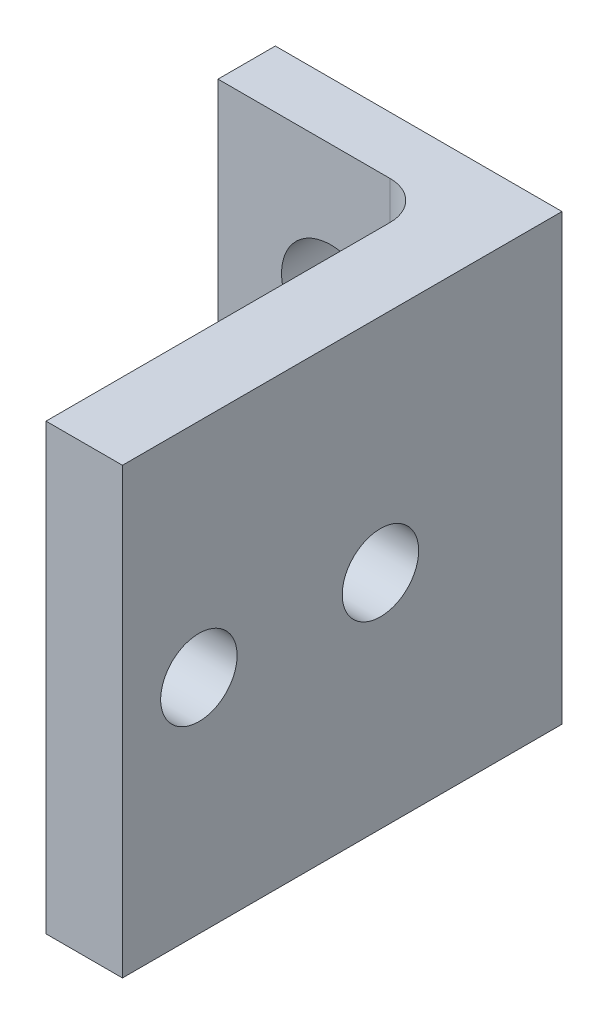
from build123d import *

# Parameters (mm, degrees)
SKETCH1_W           = 15
SKETCH1_H           = 23.236534363
SKETCH1_R           = 2.58
BOSS_EXTRUDE1_DEPTH = 3
SKETCH2_W           = 4
SKETCH2_H           = 23.236534363
BOSS_EXTRUDE2_DEPTH = 20
SKETCH3_R           = 2
CUT_EXTRUDE1_DEPTH  = 4
FILLET1_R           = 2
SKETCH4_R           = 4.75
CUT_EXTRUDE2_DEPTH  = 4


with BuildPart() as part:
    # Sketch1 → Boss-Extrude1 (new body)
    with BuildSketch(Plane.XY):
        with Locations((57.83, 7.038267182)):
            Rectangle(SKETCH1_W, SKETCH1_H)
        with Locations((56.235, 11.52)):
            Circle(SKETCH1_R, mode=Mode.SUBTRACT)
    extrude(amount=BOSS_EXTRUDE1_DEPTH)

    # Sketch2 → Boss-Extrude2 (add)
    with BuildSketch(Plane.XY.offset(3)):
        with Locations((63.33, 7.038267182)):
            Rectangle(SKETCH2_W, SKETCH2_H)
    extrude(amount=BOSS_EXTRUDE2_DEPTH)

    # Sketch3 → Cut-Extrude1 (cut)
    with BuildSketch(Plane(origin=(65.33, 0, 0), x_dir=(0, 0, -1), z_dir=(1, 0, 0))):
        with Locations((-19, 7.038267182)):
            Circle(SKETCH3_R)
        with Locations((-9.5, 7.038267182)):
            Circle(SKETCH3_R)
    extrude(amount=-CUT_EXTRUDE1_DEPTH, mode=Mode.SUBTRACT)

    # Fillet1
    fillet1_edges = [part.edges().sort_by_distance(p)[0] for p in [
        (61.33, 7.038267182, 3),
    ]]
    fillet(fillet1_edges, radius=FILLET1_R)

    # Sketch4 → Cut-Extrude2 (cut)
    with BuildSketch(Plane.XY.offset(3)):
        with Locations((56.235, 11.52)):
            Circle(SKETCH4_R)
    extrude(amount=CUT_EXTRUDE2_DEPTH, mode=Mode.SUBTRACT)


solid = part.part
